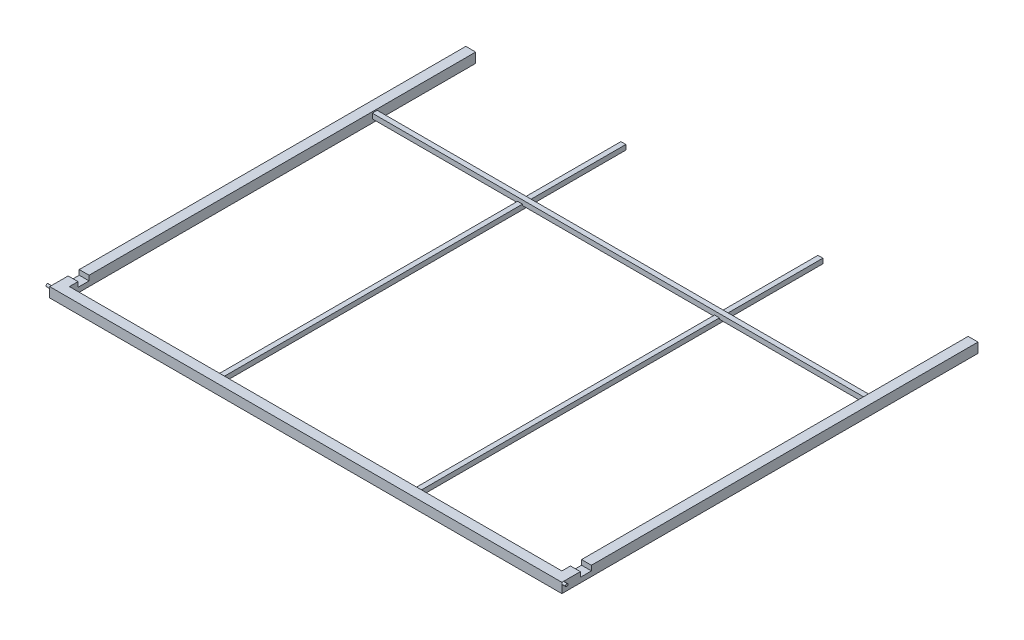
from build123d import *

# Parameters (mm, degrees)
SKETCH2_W             = 50.8
SKETCH2_H             = 50.8
SKETCH2_W_2           = 44.45
SKETCH2_H_2           = 44.45
SKETCH6_R             = 6.35
BOSS_EXTRUDE3_DEPTH   = 19.05
SKETCH12_R            = 6.35
BOSS_EXTRUDE6_DEPTH   = 19.05
SKETCH13_W            = 57.15
SKETCH13_H            = 25.4
CUT_EXTRUDE2_DEPTH    = 2641.6
SKETCH14_W            = 25.4
SKETCH14_H            = 25.4
SKETCH14_W_2          = 19.05
SKETCH14_H_2          = 19.05
BOSS_EXTRUDE7_DEPTH   = 2540
SKETCH16_W            = 25.4
SKETCH16_H            = 6.35
CUT_EXTRUDE3_DEPTH    = 25.4
SKETCH15_W            = 25.4
SKETCH15_H            = 25.4
SKETCH15_W_2          = 19.05
SKETCH15_H_2          = 19.05
BOSS_EXTRUDE9_DEPTH   = 2095.5
BOSS_EXTRUDE9_2_DEPTH = 2095.5
BOSS_EXTRUDE10_DEPTH  = 50.8
BOSS_EXTRUDE11_DEPTH  = 50.8


with BuildPart() as part:
    # Sweep1: sweep along a path in Sketch1
    with BuildLine(Plane(origin=(0, 0, 0), x_dir=(1, 0, 0), z_dir=(0, 1, 0))) as sweep1_path:
        Line((1308.1, 1066.8), (1308.1, -1066.8))
        Line((1308.1, -1066.8), (-1308.1, -1066.8))
        Line((-1308.1, -1066.8), (-1308.1, 1066.8))
    # Sketch2 → Sweep1 (sweep)
    with BuildSketch(Plane.XY):
        with Locations((-1295.4, 0)):
            Rectangle(SKETCH2_W, SKETCH2_H)
        with Locations((-1295.4, 0)):
            Rectangle(SKETCH2_W_2, SKETCH2_H_2, mode=Mode.SUBTRACT)
    sweep(path=sweep1_path.line, transition=Transition.RIGHT)

    # Sketch6 → Boss-Extrude3 (add)
    with BuildSketch(Plane.ZY.offset(1320.8)):
        with Locations((1073.15, 19.05)):
            Circle(SKETCH6_R)
    extrude(amount=BOSS_EXTRUDE3_DEPTH)

    # Sketch12 → Boss-Extrude6 (add)
    with BuildSketch(Plane(origin=(1320.8, 0, 0), x_dir=(0, 0, -1), z_dir=(1, 0, 0))):
        with Locations((-1073.15, 19.05)):
            Circle(SKETCH12_R)
    extrude(amount=BOSS_EXTRUDE6_DEPTH)

    # Sketch13 → Cut-Extrude2 (cut)
    with BuildSketch(Plane.ZY.offset(1320.8)):
        with Locations((955.675, 12.7)):
            Rectangle(SKETCH13_W, SKETCH13_H)
    extrude(amount=-CUT_EXTRUDE2_DEPTH, mode=Mode.SUBTRACT)

    # Sketch17 → Boss-Extrude10 (add)
    with BuildSketch(Plane(origin=(1320.8, 0, 0), x_dir=(0, 0, -1), z_dir=(1, 0, 0))):
        Polygon((-984.25, 25.4), (-987.425, 25.4), (-987.425, -3.175), (-923.925, -3.175), (-923.925, 25.4), (-927.1, 25.4), (-927.1, 0), (-984.25, 0), align=None)
    extrude(amount=-BOSS_EXTRUDE10_DEPTH)

    # Sketch18 → Boss-Extrude11 (add)
    with BuildSketch(Plane.ZY.offset(1320.8)):
        Polygon((927.1, 25.4), (923.925, 25.4), (923.925, -3.175), (987.425, -3.175), (987.425, 25.4), (984.25, 25.4), (984.25, 0), (927.1, 0), align=None)
    extrude(amount=-BOSS_EXTRUDE11_DEPTH)


with BuildPart() as body_2:
    # Sketch14 → Boss-Extrude7 (new body)
    with BuildSketch(Plane.ZY.offset(-1270)):
        with Locations((-546.1, 6.35)):
            Rectangle(SKETCH14_W, SKETCH14_H)
        with Locations((-546.1, 6.35)):
            Rectangle(SKETCH14_W_2, SKETCH14_H_2, mode=Mode.SUBTRACT)
    extrude(amount=BOSS_EXTRUDE7_DEPTH)

    # Sketch16 → Cut-Extrude3 (cut)
    with BuildSketch(Plane(origin=(0, 0, -558.8), x_dir=(-1, 0, 0), z_dir=(0, 0, -1))):
        with Locations((-508, -3.175)):
            Rectangle(SKETCH16_W, SKETCH16_H)
        with Locations((508, -3.175)):
            Rectangle(SKETCH16_W, SKETCH16_H)
    extrude(amount=-CUT_EXTRUDE3_DEPTH, mode=Mode.SUBTRACT)


with BuildPart() as body_3:
    # Sketch15 → Boss-Extrude9 (new body)
    with BuildSketch(Plane(origin=(0, 0, 1028.7), x_dir=(-1, 0, 0), z_dir=(0, 0, -1))):
        with Locations((-508, -12.7)):
            Rectangle(SKETCH15_W, SKETCH15_H)
        with Locations((-508, -12.7)):
            Rectangle(SKETCH15_W_2, SKETCH15_H_2, mode=Mode.SUBTRACT)
    extrude(amount=BOSS_EXTRUDE9_DEPTH)


with BuildPart() as body_4:
    # Sketch15 → Boss-Extrude9 2 (new body)
    with BuildSketch(Plane(origin=(0, 0, 1028.7), x_dir=(-1, 0, 0), z_dir=(0, 0, -1))):
        with Locations((508, -12.7)):
            Rectangle(SKETCH15_W, SKETCH15_H)
        with Locations((508, -12.7)):
            Rectangle(SKETCH15_W_2, SKETCH15_H_2, mode=Mode.SUBTRACT)
    extrude(amount=BOSS_EXTRUDE9_2_DEPTH)


solid = Compound([part.part, body_2.part, body_3.part, body_4.part])
